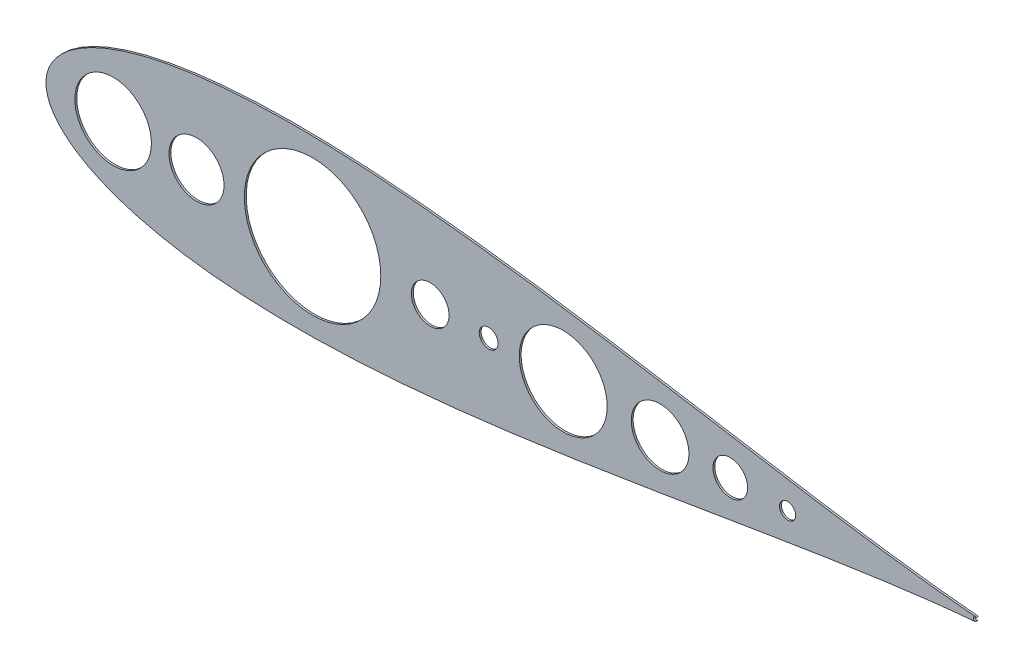
from build123d import *

# Parameters (mm, degrees)
SKETCH3_R           = 51.572420782
SKETCH3_R_2         = 25.4
SKETCH3_R_3         = 38.839867238
SKETCH3_R_4         = 59.233902528
SKETCH3_R_5         = 91.963345756
SKETCH3_R_6         = 10.885648066
SKETCH3_R_7         = 37.084
SKETCH3_R_8         = 23.371474882
SKETCH3_R_9         = 12.7
BOSS_EXTRUDE1_DEPTH = 2.54


with BuildPart() as part:
    # Sketch3 → Boss-Extrude1 (new body)
    with BuildSketch(Plane.XY):
        with BuildLine():
            ThreePointArc((1753.591461253, 1065.776083909), (1749.872780279, 1063.590003474), (1753.591461253, 1061.403923038))
            ThreePointArc((1753.591461253, 1061.403923038), (1752.70544976, 1060.784672033), (1751.66043944, 1060.508191283))
            add(Edge.make_bspline(
                [(1751.66043944, 1066.671815664), (1750.652433341, 1066.755641055), (1743.055888013, 1067.395511868), (1728.09542145, 1068.778278407), (1705.888818963, 1071.088349604), (1681.267782657, 1073.923031126), (1654.324866096, 1077.299316265), (1625.185769612, 1081.220642681), (1593.976504425, 1085.678218896), (1560.832217929, 1090.649019617), (1525.89365688, 1096.097683493), (1489.307193406, 1101.975560986), (1451.224024677, 1108.221941693), (1411.799733382, 1114.764812911), (1371.193783626, 1121.521589944), (1329.569253716, 1128.400594853), (1287.092567941, 1135.302157088), (1243.933356277, 1142.120247303), (1200.26436245, 1148.743906399), (1156.261437039, 1155.059215112), (1112.103516884, 1160.950739374), (1067.972668522, 1166.303587813), (1024.054118421, 1171.005063037), (980.536281285, 1174.946651725), (937.610742062, 1178.025607563), (895.472252218, 1180.146872538), (854.318687371, 1181.224865431), (814.350979978, 1181.184844126), (775.773186932, 1179.963320532), (738.792492743, 1177.512468252), (703.619811591, 1173.796747526), (670.470121338, 1168.799409234), (639.564473005, 1162.518700368), (611.131491578, 1154.975637358), (585.41155007, 1146.214428258), (562.66122996, 1136.313136914), (543.156806202, 1125.402878466), (527.189666059, 1113.705054249), (515.028677955, 1101.601731933), (506.795494631, 1089.732853878), (502.204442162, 1079.024766085), (500.350488396, 1070.434879272), (499.928233722, 1063.590003466), (500.350488396, 1056.74512766), (502.204442162, 1048.155240847), (506.795494631, 1037.447153055), (515.028677955, 1025.578274999), (527.189666059, 1013.474952684), (543.156806202, 1001.777128466), (562.66122996, 990.866870018), (585.41155007, 980.965578674), (611.131491578, 972.204369574), (639.564473005, 964.661306564), (670.470121338, 958.380597698), (703.619811591, 953.383259406), (738.792492743, 949.66753868), (775.773186932, 947.2166864), (814.350979978, 945.995162807), (854.318687371, 945.955141501), (895.472252218, 947.033134394), (937.610742062, 949.154399369), (980.536281285, 952.233355208), (1024.054118421, 956.174943896), (1067.972668522, 960.876419119), (1112.103516884, 966.229267558), (1156.261437039, 972.12079182), (1200.26436245, 978.436100533), (1243.933356277, 985.05975963), (1287.092567941, 991.877849844), (1329.569253716, 998.779412079), (1371.193783626, 1005.658416989), (1411.799733382, 1012.415194021), (1451.224024677, 1018.95806524), (1489.307193406, 1025.204445947), (1525.89365688, 1031.082323439), (1560.832217929, 1036.530987316), (1593.976504425, 1041.501788037), (1625.185769612, 1045.959364252), (1654.324866096, 1049.880690667), (1681.267782657, 1053.256975806), (1705.888818963, 1056.091657329), (1728.09542145, 1058.401728525), (1743.055888013, 1059.784495064), (1750.652433341, 1060.424365878), (1751.66043944, 1060.508191283)],
                knots=[0.020157042, 0.020157042, 0.020157042, 0.020157042, 0.021270888, 0.028552555, 0.036780684, 0.045920102, 0.055931764, 0.066772884, 0.07839713, 0.090754827, 0.103793165, 0.117456432, 0.131686226, 0.146421738, 0.161599998, 0.177156133, 0.193023668, 0.209134786, 0.225420633, 0.241811602, 0.258237647, 0.274628557, 0.290914287, 0.307025229, 0.322892517, 0.338448342, 0.353626207, 0.368361232, 0.382590428, 0.396252961, 0.409290412, 0.42164701, 0.433269881, 0.444109249, 0.45411864, 0.463255055, 0.471479114, 0.478755289, 0.485052318, 0.490344026, 0.494609833, 0.497833231, 0.5, 0.502166769, 0.505390167, 0.509655974, 0.514947682, 0.521244711, 0.528520886, 0.536744945, 0.54588136, 0.555890751, 0.566730119, 0.57835299, 0.590709588, 0.603747039, 0.617409572, 0.631638768, 0.646373793, 0.661551658, 0.677107483, 0.692974771, 0.709085713, 0.725371443, 0.741762353, 0.758188398, 0.774579367, 0.790865214, 0.806976332, 0.822843867, 0.838400002, 0.853578262, 0.868313774, 0.882543568, 0.896206835, 0.909245173, 0.92160287, 0.933227116, 0.944068236, 0.954079898, 0.963219316, 0.971447445, 0.978729112, 0.979842958, 0.979842958, 0.979842958, 0.979842958], degree=3))
            ThreePointArc((1751.66043944, 1066.671815664), (1752.70544976, 1066.395334914), (1753.591461253, 1065.776083909))
        make_face()
        with Locations((590.532537967, 1063.590003474)):
            Circle(SKETCH3_R, mode=Mode.SUBTRACT)
        with Locations((1017.874025025, 1063.590003474)):
            Circle(SKETCH3_R_2, mode=Mode.SUBTRACT)
        with Locations((1327.69021037, 1063.590003474)):
            Circle(SKETCH3_R_3, mode=Mode.SUBTRACT)
        with Locations((1197.117612222, 1063.590003474)):
            Circle(SKETCH3_R_4, mode=Mode.SUBTRACT)
        with Locations((859.292016134, 1063.590003474)):
            Circle(SKETCH3_R_5, mode=Mode.SUBTRACT)
        with Locations((1499.519670337, 1063.590003474)):
            Circle(SKETCH3_R_6, mode=Mode.SUBTRACT)
        with Locations((702.914025025, 1063.590003474)):
            Circle(SKETCH3_R_7, mode=Mode.SUBTRACT)
        with Locations((1422.271759301, 1063.590003474)):
            Circle(SKETCH3_R_8, mode=Mode.SUBTRACT)
        with Locations((1096.614025025, 1063.590003474)):
            Circle(SKETCH3_R_9, mode=Mode.SUBTRACT)
    extrude(amount=BOSS_EXTRUDE1_DEPTH)


solid = part.part
